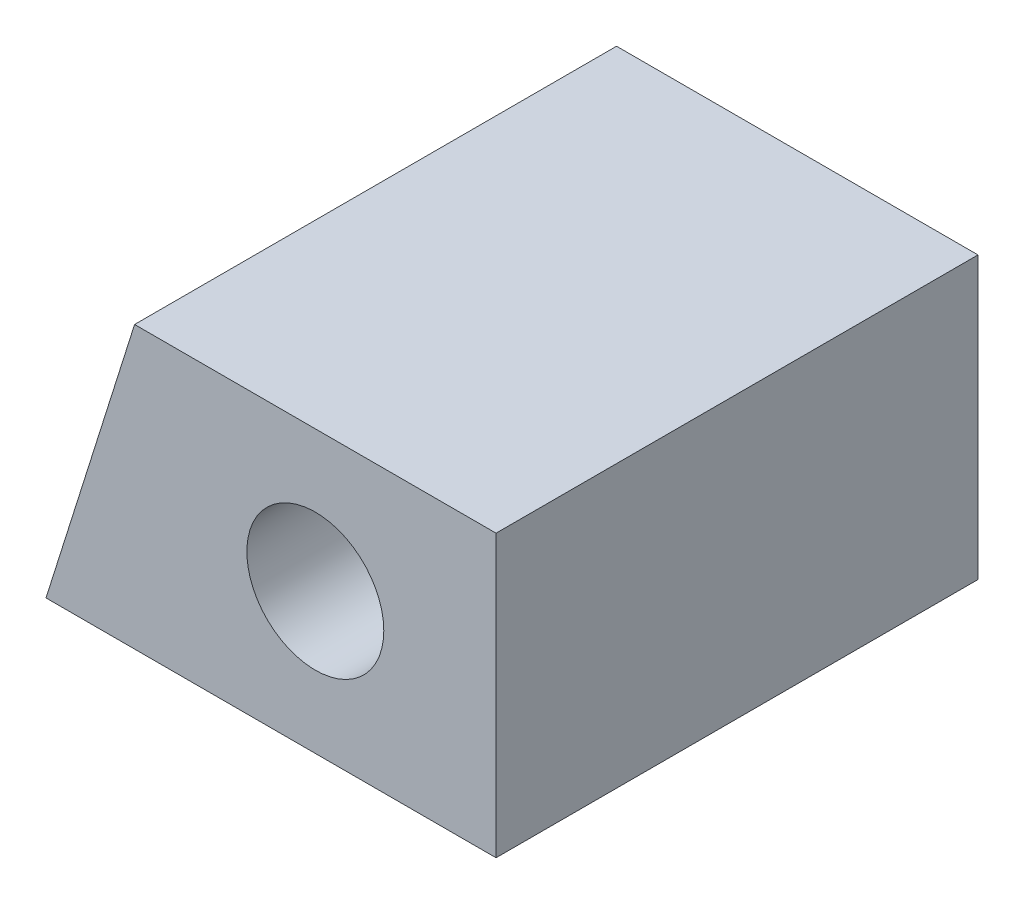
from build123d import *

# Parameters (mm, degrees)
SKETCH1_R           = 1.705
BOSS_EXTRUDE1_DEPTH = 12


with BuildPart() as part:
    # Sketch1 → Boss-Extrude1 (new body)
    with BuildSketch(Plane.XY):
        Polygon((-3.397125795, 3.5), (-5.602874205, -3.5), (5.602874205, -3.5), (5.602874205, 3.5), align=None)
        with Locations((1.102874205, 0)):
            Circle(SKETCH1_R, mode=Mode.SUBTRACT)
    extrude(amount=BOSS_EXTRUDE1_DEPTH)


solid = part.part
